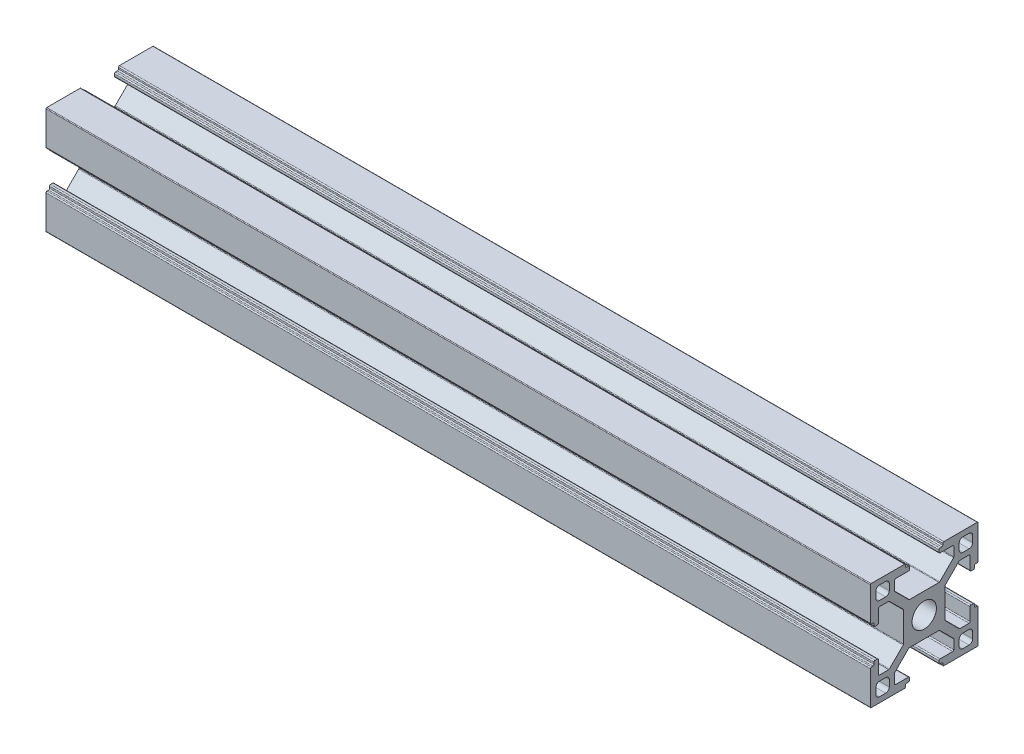
from build123d import *

# Parameters (mm, degrees)
SKETCH_11_R          = 3.4
MEMBER_3030A_1_DEPTH = 230


with BuildPart() as part:
    # 草图11 → Member 3030a _1 (new body)
    with BuildSketch(Plane.YZ):
        with BuildLine():
            Line((0, 5.8), (-4.120101013, 5.8))
            ThreePointArc((-4.120101013, 5.8), (-4.234906042, 5.82283614), (-4.332233047, 5.887867966))
            Line((-4.332233047, 5.887867966), (-8.162132034, 9.717766953))
            ThreePointArc((-8.162132034, 9.717766953), (-8.22716386, 9.815093958), (-8.25, 9.929898987))
            Line((-8.25, 9.929898987), (-8.25, 12.5))
            ThreePointArc((-8.25, 12.5), (-8.162132034, 12.712132034), (-7.95, 12.8))
            Line((-7.95, 12.8), (-4.4, 12.8))
            ThreePointArc((-4.4, 12.8), (-4.187867966, 12.887867966), (-4.1, 13.1))
            Line((-4.1, 13.1), (-4.1, 13.7))
            ThreePointArc((-4.1, 13.7), (-4.187867966, 13.912132034), (-4.4, 14))
            Line((-4.4, 14), (-4.9, 14))
            ThreePointArc((-4.9, 14), (-5.112132034, 14.087867966), (-5.2, 14.3))
            Line((-5.2, 14.3), (-5.2, 14.7))
            ThreePointArc((-5.2, 14.7), (-5.287867966, 14.912132034), (-5.5, 15))
            Line((-5.5, 15), (-14.8, 15))
            ThreePointArc((-14.8, 15), (-14.941421356, 14.941421356), (-15, 14.8))
            Line((-15, 14.8), (-15, 5.5))
            ThreePointArc((-15, 5.5), (-14.912132034, 5.287867966), (-14.7, 5.2))
            Line((-14.7, 5.2), (-14.3, 5.2))
            ThreePointArc((-14.3, 5.2), (-14.087867966, 5.112132034), (-14, 4.9))
            Line((-14, 4.9), (-14, 4.4))
            ThreePointArc((-14, 4.4), (-13.912132034, 4.187867966), (-13.7, 4.1))
            Line((-13.7, 4.1), (-13.1, 4.1))
            ThreePointArc((-13.1, 4.1), (-12.887867966, 4.187867966), (-12.8, 4.4))
            Line((-12.8, 4.4), (-12.8, 7.95))
            ThreePointArc((-12.8, 7.95), (-12.712132034, 8.162132034), (-12.5, 8.25))
            Line((-12.5, 8.25), (-9.929898987, 8.25))
            ThreePointArc((-9.929898987, 8.25), (-9.815093957, 8.227163859), (-9.717766953, 8.162132034))
            Line((-9.717766953, 8.162132034), (-5.887867966, 4.332233047))
            ThreePointArc((-5.887867966, 4.332233047), (-5.82283614, 4.234906042), (-5.8, 4.120101013))
            Line((-5.8, 4.120101013), (-5.8, 0))
            Line((-5.8, 0), (-5.8, -4.120101013))
            ThreePointArc((-5.8, -4.120101013), (-5.82283614, -4.234906042), (-5.887867966, -4.332233047))
            Line((-5.887867966, -4.332233047), (-9.717766953, -8.162132034))
            ThreePointArc((-9.717766953, -8.162132034), (-9.815093958, -8.22716386), (-9.929898988, -8.25))
            Line((-9.929898988, -8.25), (-12.5, -8.25))
            ThreePointArc((-12.5, -8.25), (-12.712132034, -8.162132034), (-12.8, -7.95))
            Line((-12.8, -7.95), (-12.8, -4.4))
            ThreePointArc((-12.8, -4.4), (-12.887867966, -4.187867966), (-13.1, -4.1))
            Line((-13.1, -4.1), (-13.7, -4.1))
            ThreePointArc((-13.7, -4.1), (-13.912132034, -4.187867966), (-14, -4.4))
            Line((-14, -4.4), (-14, -4.9))
            ThreePointArc((-14, -4.9), (-14.087867966, -5.112132034), (-14.3, -5.2))
            Line((-14.3, -5.2), (-14.7, -5.2))
            ThreePointArc((-14.7, -5.2), (-14.912132034, -5.287867966), (-15, -5.5))
            Line((-15, -5.5), (-15, -14.8))
            ThreePointArc((-15, -14.8), (-14.941421356, -14.941421356), (-14.8, -15))
            Line((-14.8, -15), (-5.5, -15))
            ThreePointArc((-5.5, -15), (-5.287867966, -14.912132034), (-5.2, -14.7))
            Line((-5.2, -14.7), (-5.2, -14.3))
            ThreePointArc((-5.2, -14.3), (-5.112132034, -14.087867966), (-4.9, -14))
            Line((-4.9, -14), (-4.4, -14))
            ThreePointArc((-4.4, -14), (-4.187867966, -13.912132034), (-4.1, -13.7))
            Line((-4.1, -13.7), (-4.1, -13.1))
            ThreePointArc((-4.1, -13.1), (-4.187867966, -12.887867966), (-4.4, -12.8))
            Line((-4.4, -12.8), (-7.95, -12.8))
            ThreePointArc((-7.95, -12.8), (-8.162132034, -12.712132034), (-8.25, -12.5))
            Line((-8.25, -12.5), (-8.25, -9.929898987))
            ThreePointArc((-8.25, -9.929898987), (-8.22716386, -9.815093958), (-8.162132034, -9.717766953))
            Line((-8.162132034, -9.717766953), (-4.332233047, -5.887867966))
            ThreePointArc((-4.332233047, -5.887867966), (-4.234906042, -5.82283614), (-4.120101013, -5.8))
            Line((-4.120101013, -5.8), (0, -5.8))
            Line((0, -5.8), (4.120101013, -5.8))
            ThreePointArc((4.120101013, -5.8), (4.234906042, -5.82283614), (4.332233047, -5.887867966))
            Line((4.332233047, -5.887867966), (8.162132034, -9.717766953))
            ThreePointArc((8.162132034, -9.717766953), (8.22716386, -9.815093958), (8.25, -9.929898987))
            Line((8.25, -9.929898987), (8.25, -12.5))
            ThreePointArc((8.25, -12.5), (8.162132034, -12.712132034), (7.95, -12.8))
            Line((7.95, -12.8), (4.4, -12.8))
            ThreePointArc((4.4, -12.8), (4.187867966, -12.887867966), (4.1, -13.1))
            Line((4.1, -13.1), (4.1, -13.7))
            ThreePointArc((4.1, -13.7), (4.187867966, -13.912132034), (4.4, -14))
            Line((4.4, -14), (4.9, -14))
            ThreePointArc((4.9, -14), (5.112132034, -14.087867966), (5.2, -14.3))
            Line((5.2, -14.3), (5.2, -14.7))
            ThreePointArc((5.2, -14.7), (5.287867966, -14.912132034), (5.5, -15))
            Line((5.5, -15), (14.8, -15))
            ThreePointArc((14.8, -15), (14.941421356, -14.941421356), (15, -14.8))
            Line((15, -14.8), (15, -5.5))
            ThreePointArc((15, -5.5), (14.912132034, -5.287867966), (14.7, -5.2))
            Line((14.7, -5.2), (14.3, -5.2))
            ThreePointArc((14.3, -5.2), (14.087867966, -5.112132034), (14, -4.9))
            Line((14, -4.9), (14, -4.4))
            ThreePointArc((14, -4.4), (13.912132034, -4.187867966), (13.7, -4.1))
            Line((13.7, -4.1), (13.1, -4.1))
            ThreePointArc((13.1, -4.1), (12.887867966, -4.187867966), (12.8, -4.4))
            Line((12.8, -4.4), (12.8, -7.95))
            ThreePointArc((12.8, -7.95), (12.712132034, -8.162132034), (12.5, -8.25))
            Line((12.5, -8.25), (9.929898987, -8.25))
            ThreePointArc((9.929898987, -8.25), (9.815093957, -8.227163859), (9.717766953, -8.162132034))
            Line((9.717766953, -8.162132034), (5.887867966, -4.332233047))
            ThreePointArc((5.887867966, -4.332233047), (5.82283614, -4.234906042), (5.8, -4.120101013))
            Line((5.8, -4.120101013), (5.8, 0))
            Line((5.8, 0), (5.8, 4.120101013))
            ThreePointArc((5.8, 4.120101013), (5.82283614, 4.234906042), (5.887867966, 4.332233047))
            Line((5.887867966, 4.332233047), (9.805634919, 8.25))
            Line((9.805634919, 8.25), (12.5, 8.25))
            ThreePointArc((12.5, 8.25), (12.712132034, 8.162132034), (12.8, 7.95))
            Line((12.8, 7.95), (12.8, 4.4))
            ThreePointArc((12.8, 4.4), (12.887867966, 4.187867966), (13.1, 4.1))
            Line((13.1, 4.1), (13.7, 4.1))
            ThreePointArc((13.7, 4.1), (13.912132034, 4.187867966), (14, 4.4))
            Line((14, 4.4), (14, 4.9))
            ThreePointArc((14, 4.9), (14.087867966, 5.112132034), (14.3, 5.2))
            Line((14.3, 5.2), (14.7, 5.2))
            ThreePointArc((14.7, 5.2), (14.912132034, 5.287867966), (15, 5.5))
            Line((15, 5.5), (15, 14.8))
            ThreePointArc((15, 14.8), (14.941421356, 14.941421356), (14.8, 15))
            Line((14.8, 15), (5.5, 15))
            ThreePointArc((5.5, 15), (5.287867966, 14.912132034), (5.2, 14.7))
            Line((5.2, 14.7), (5.2, 14.3))
            ThreePointArc((5.2, 14.3), (5.112132034, 14.087867966), (4.9, 14))
            Line((4.9, 14), (4.4, 14))
            ThreePointArc((4.4, 14), (4.187867966, 13.912132034), (4.1, 13.7))
            Line((4.1, 13.7), (4.1, 13.1))
            ThreePointArc((4.1, 13.1), (4.187867966, 12.887867966), (4.4, 12.8))
            Line((4.4, 12.8), (7.95, 12.8))
            ThreePointArc((7.95, 12.8), (8.162132034, 12.712132034), (8.25, 12.5))
            Line((8.25, 12.5), (8.25, 9.929898987))
            ThreePointArc((8.25, 9.929898987), (8.22716386, 9.815093958), (8.162132034, 9.717766953))
            Line((8.162132034, 9.717766953), (4.332233047, 5.887867966))
            ThreePointArc((4.332233047, 5.887867966), (4.234906042, 5.82283614), (4.120101013, 5.8))
            Line((4.120101013, 5.8), (0, 5.8))
        make_face()
        Circle(SKETCH_11_R, mode=Mode.SUBTRACT)
        with BuildLine():
            Line((-10.75, -13.5), (-12.5, -13.5))
            ThreePointArc((-12.5, -13.5), (-13.207106781, -13.207106781), (-13.5, -12.5))
            Line((-13.5, -12.5), (-13.5, -10.75))
            ThreePointArc((-13.5, -10.75), (-13.207106781, -10.042893219), (-12.5, -9.75))
            Line((-12.5, -9.75), (-10.75, -9.75))
            ThreePointArc((-10.75, -9.75), (-10.042893219, -10.042893219), (-9.75, -10.75))
            Line((-9.75, -10.75), (-9.75, -12.5))
            ThreePointArc((-9.75, -12.5), (-10.042893219, -13.207106781), (-10.75, -13.5))
        make_face(mode=Mode.SUBTRACT)
        with BuildLine():
            Line((10.75, -13.5), (12.5, -13.5))
            ThreePointArc((12.5, -13.5), (13.207106781, -13.207106781), (13.5, -12.5))
            Line((13.5, -12.5), (13.5, -10.75))
            ThreePointArc((13.5, -10.75), (13.207106781, -10.042893219), (12.5, -9.75))
            Line((12.5, -9.75), (10.75, -9.75))
            ThreePointArc((10.75, -9.75), (10.042893219, -10.042893219), (9.75, -10.75))
            Line((9.75, -10.75), (9.75, -12.5))
            ThreePointArc((9.75, -12.5), (10.042893219, -13.207106781), (10.75, -13.5))
        make_face(mode=Mode.SUBTRACT)
        with BuildLine():
            Line((-10.75, 13.5), (-12.5, 13.5))
            ThreePointArc((-12.5, 13.5), (-13.207106781, 13.207106781), (-13.5, 12.5))
            Line((-13.5, 12.5), (-13.5, 10.75))
            ThreePointArc((-13.5, 10.75), (-13.207106781, 10.042893219), (-12.5, 9.75))
            Line((-12.5, 9.75), (-10.75, 9.75))
            ThreePointArc((-10.75, 9.75), (-10.042893219, 10.042893219), (-9.75, 10.75))
            Line((-9.75, 10.75), (-9.75, 12.5))
            ThreePointArc((-9.75, 12.5), (-10.042893219, 13.207106781), (-10.75, 13.5))
        make_face(mode=Mode.SUBTRACT)
        with BuildLine():
            Line((10.75, 13.5), (12.5, 13.5))
            ThreePointArc((12.5, 13.5), (13.207106781, 13.207106781), (13.5, 12.5))
            Line((13.5, 12.5), (13.5, 10.75))
            ThreePointArc((13.5, 10.75), (13.207106781, 10.042893219), (12.5, 9.75))
            Line((12.5, 9.75), (10.75, 9.75))
            ThreePointArc((10.75, 9.75), (10.042893219, 10.042893219), (9.75, 10.75))
            Line((9.75, 10.75), (9.75, 12.5))
            ThreePointArc((9.75, 12.5), (10.042893219, 13.207106781), (10.75, 13.5))
        make_face(mode=Mode.SUBTRACT)
    extrude(amount=MEMBER_3030A_1_DEPTH)


solid = part.part
